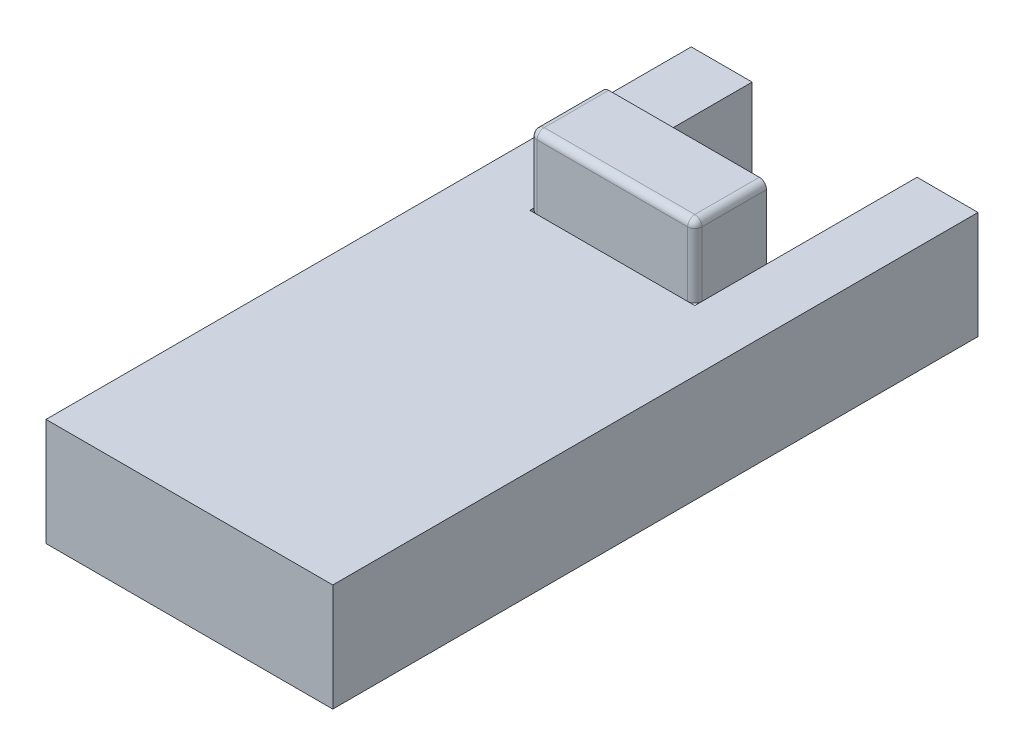
from build123d import *

# Parameters (mm, degrees)
CROQUIS2_W              = 400
CROQUIS2_H              = 900
SALIENTE_EXTRUIR1_DEPTH = 150
CROQUIS3_W              = 230
CROQUIS3_H              = 620
CORTAR_EXTRUIR1_DEPTH   = 150
CROQUIS9_W              = 230
CROQUIS9_H              = 100
SALIENTE_EXTRUIR6_DEPTH = 100
REDONDEO1_R             = 10
REDONDEO2_R             = 10
REDONDEO3_R             = 10


with BuildPart() as part:
    # Croquis2 → Saliente-Extruir1 (new body)
    with BuildSketch(Plane(origin=(0, 0, 0), x_dir=(1, 0, 0), z_dir=(0, 1, 0))):
        Rectangle(CROQUIS2_W, CROQUIS2_H)
    extrude(amount=SALIENTE_EXTRUIR1_DEPTH)

    # Croquis3 → Cortar-Extruir1 (cut)
    with BuildSketch(Plane.XZ):
        with Locations((0, -450)):
            Rectangle(CROQUIS3_W, CROQUIS3_H)
    extrude(amount=-CORTAR_EXTRUIR1_DEPTH, mode=Mode.SUBTRACT)


with BuildPart() as body_2:
    # Croquis9 → Saliente-Extruir6 (new body)
    with BuildSketch(Plane(origin=(0, 150, 0), x_dir=(1, 0, 0), z_dir=(0, 1, 0))):
        with Locations((0, 190)):
            Rectangle(CROQUIS9_W, CROQUIS9_H)
    extrude(amount=SALIENTE_EXTRUIR6_DEPTH)

    # Redondeo1
    redondeo1_edges = [body_2.edges().sort_by_distance(p)[0] for p in [
        (-115, 250, -190),
    ]]
    fillet(redondeo1_edges, radius=REDONDEO1_R)

    # Redondeo2
    redondeo2_edges = [body_2.edges().sort_by_distance(p)[0] for p in [
        (-115, 195, -140),
        (5, 250, -140),
    ]]
    fillet(redondeo2_edges, radius=REDONDEO2_R)

    # Redondeo3
    redondeo3_edges = [body_2.edges().sort_by_distance(p)[0] for p in [
        (115, 195, -140),
        (115, 250, -195),
    ]]
    fillet(redondeo3_edges, radius=REDONDEO3_R)


solid = Compound([part.part, body_2.part])
